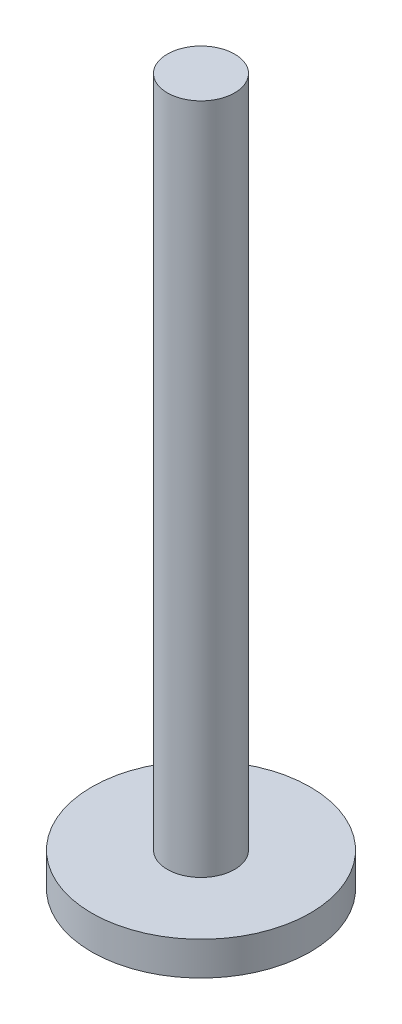
from build123d import *

# Parameters (mm, degrees)
SKETCH3_R           = 41.275
BOSS_EXTRUDE3_DEPTH = 12.7
SKETCH4_R           = 12.7
BOSS_EXTRUDE4_DEPTH = 254


with BuildPart() as part:
    # Sketch3 → Boss-Extrude3 (new body)
    with BuildSketch(Plane(origin=(0, 0, 0), x_dir=(1, 0, 0), z_dir=(0, 1, 0))):
        Circle(SKETCH3_R)
    extrude(amount=BOSS_EXTRUDE3_DEPTH)

    # Sketch4 → Boss-Extrude4 (add)
    with BuildSketch(Plane(origin=(0, 12.7, 0), x_dir=(1, 0, 0), z_dir=(0, 1, 0))):
        Circle(SKETCH4_R)
    extrude(amount=BOSS_EXTRUDE4_DEPTH)


solid = part.part
